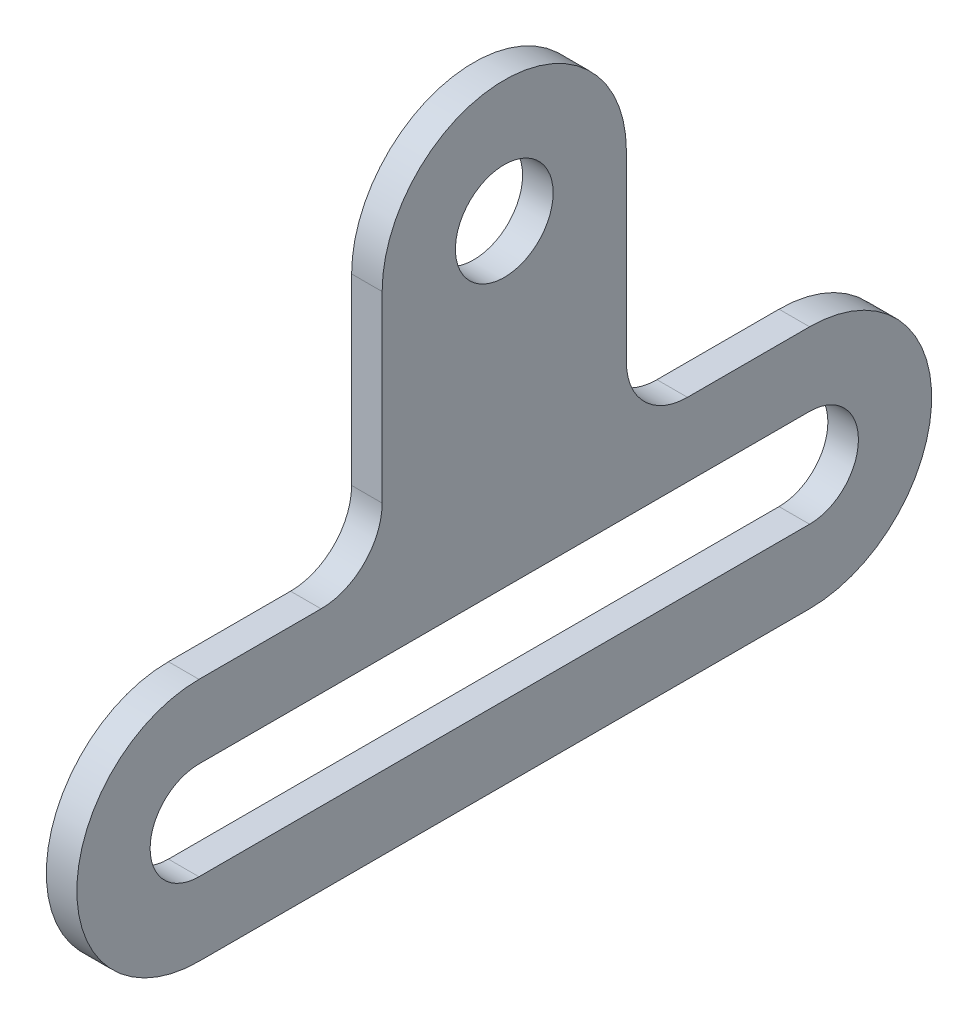
from build123d import *

# Parameters (mm, degrees)
SKETCH1_R           = 1.6
BOSS_EXTRUDE1_DEPTH = 0.5


with BuildPart() as part:
    # Sketch1 → Boss-Extrude1 (new body, symmetric)
    with BuildSketch(Plane(origin=(0, 0, 0), x_dir=(0, 0, -1), z_dir=(1, 0, 0))):
        with BuildLine():
            Line((-10, 4), (-6, 4))
            ThreePointArc((-6, 4), (-4.585786438, 4.585786438), (-4, 6))
            Line((-4, 6), (-4, 12))
            ThreePointArc((-4, 12), (0, 16), (4, 12))
            Line((4, 12), (4, 6))
            ThreePointArc((4, 6), (4.585786438, 4.585786438), (6, 4))
            Line((6, 4), (10, 4))
            ThreePointArc((10, 4), (14, 0), (10, -4))
            Line((10, -4), (-10, -4))
            ThreePointArc((-10, -4), (-14, 0), (-10, 4))
        make_face()
        with Locations((0, 12)):
            Circle(SKETCH1_R, mode=Mode.SUBTRACT)
        with BuildLine():
            Line((-10, 1.6), (10, 1.6))
            ThreePointArc((10, 1.6), (11.6, 0), (10, -1.6))
            Line((10, -1.6), (-10, -1.6))
            ThreePointArc((-10, -1.6), (-11.6, 0), (-10, 1.6))
        make_face(mode=Mode.SUBTRACT)
    extrude(amount=BOSS_EXTRUDE1_DEPTH, both=True)


solid = part.part
